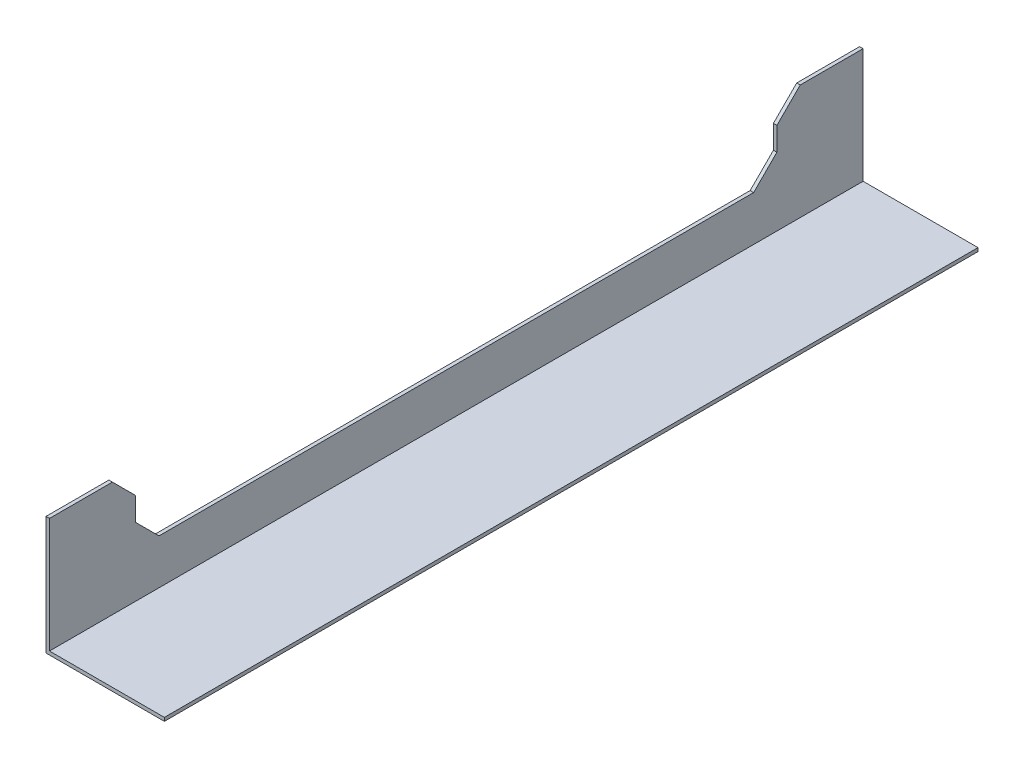
from build123d import *

# Parameters (mm, degrees)
SALIENTE_EXTRUIR1_DEPTH    = 349.2
CROQUIS5_W                 = 275.2
CROQUIS5_H                 = 30
CORTAR_EXTRUIR2_DEPTH      = 1
CORTAR_EXTRUIR2_DEPTH_BACK = 2
CHAFL_N1_SIZE              = 10


with BuildPart() as part:
    # Croquis1 → Saliente-Extruir1 (new body)
    with BuildSketch(Plane.XY):
        Polygon((0, 0), (0, 50.8), (1.5, 50.8), (1.5, 1.5), (50.8, 1.5), (50.8, 0), align=None)
    extrude(amount=SALIENTE_EXTRUIR1_DEPTH)

    # Croquis5 → Cortar-Extruir2 (cut, two sides)
    with BuildSketch(Plane.ZY) as cortar_extruir2_sk:
        with Locations((174.6, 35.8)):
            Rectangle(CROQUIS5_W, CROQUIS5_H)
    extrude(amount=CORTAR_EXTRUIR2_DEPTH, mode=Mode.SUBTRACT)
    extrude(cortar_extruir2_sk.sketch, amount=-CORTAR_EXTRUIR2_DEPTH_BACK, mode=Mode.SUBTRACT)

    # Chaflán1
    chafl_n1_edges = [part.edges().sort_by_distance(p)[0] for p in [
        (0.75, 20.8, 37),
        (0.75, 20.8, 312.2),
        (0.75, 50.8, 312.2),
        (0.75, 50.8, 37),
    ]]
    chamfer(chafl_n1_edges, length=CHAFL_N1_SIZE)


solid = part.part
